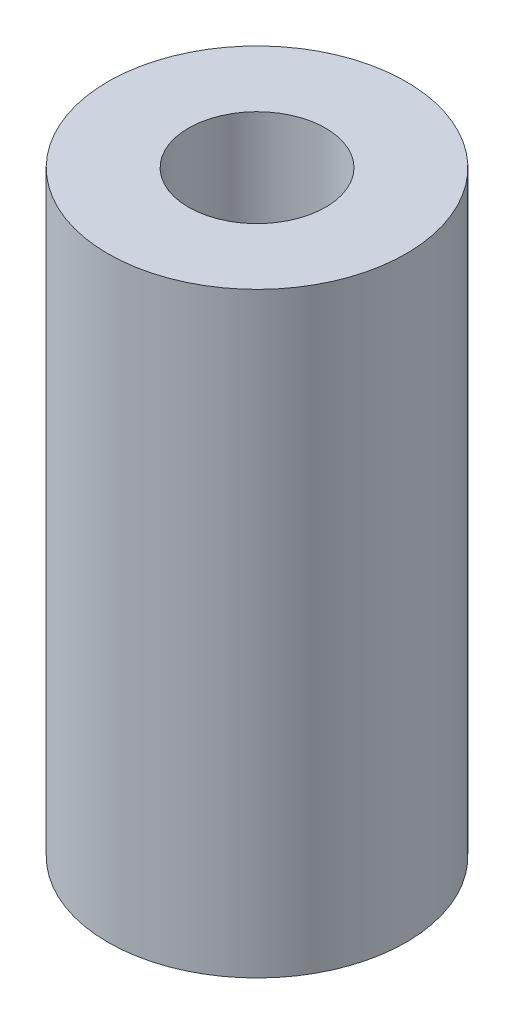
from build123d import *

# Parameters (mm, degrees)
SKETCH1_R           = 2.5
SKETCH1_R_2         = 1.15
BOSS_EXTRUDE1_DEPTH = 10


with BuildPart() as part:
    # Sketch1 → Boss-Extrude1 (new body)
    with BuildSketch(Plane(origin=(0, 0, 0), x_dir=(1, 0, 0), z_dir=(0, 1, 0))):
        Circle(SKETCH1_R)
        Circle(SKETCH1_R_2, mode=Mode.SUBTRACT)
    extrude(amount=BOSS_EXTRUDE1_DEPTH)


solid = part.part
